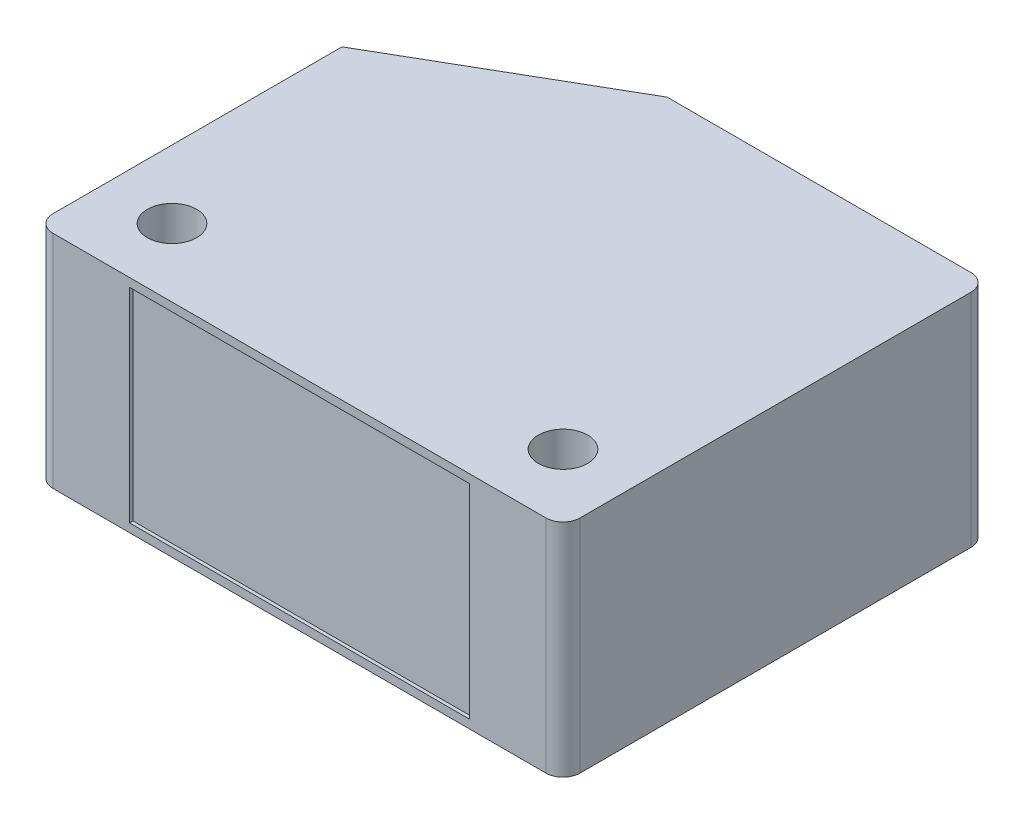
from build123d import *

# Parameters (mm, degrees)
SKETCH1_W           = 31
SKETCH1_H           = 25
SKETCH1_R           = 1.45
BOSS_EXTRUDE1_DEPTH = 13
SKETCH2_W           = 20
SKETCH2_H           = 12
CUT_EXTRUDE1_DEPTH  = 0.2
CUT_EXTRUDE2_DEPTH  = 14
FILLET1_R           = 1


with BuildPart() as part:
    # Sketch1 → Boss-Extrude1 (new body)
    with BuildSketch(Plane(origin=(0, 0, 0), x_dir=(1, 0, 0), z_dir=(0, 1, 0))):
        with Locations((0, -1.439483729)):
            Rectangle(SKETCH1_W, SKETCH1_H)
        with Locations((-11.5, -9.939483729)):
            Circle(SKETCH1_R, mode=Mode.SUBTRACT)
        with Locations((11.5, -9.939483729)):
            Circle(SKETCH1_R, mode=Mode.SUBTRACT)
    extrude(amount=BOSS_EXTRUDE1_DEPTH)

    # Sketch2 → Cut-Extrude1 (cut)
    with BuildSketch(Plane.XY.offset(13.939483729)):
        with Locations((0, 6.5)):
            Rectangle(SKETCH2_W, SKETCH2_H)
    extrude(amount=-CUT_EXTRUDE1_DEPTH, mode=Mode.SUBTRACT)

    # Sketch3 → Cut-Extrude2 (cut, through all)
    with BuildSketch(Plane(origin=(0, 13, 0), x_dir=(1, 0, 0), z_dir=(0, 1, 0))):
        Polygon((-15.5, 4.060516271), (-3.375644347, 11.060516271), (-15.5, 11.060516271), align=None)
    extrude(amount=-CUT_EXTRUDE2_DEPTH, mode=Mode.SUBTRACT)

    # Fillet1
    fillet1_edges = [part.edges().sort_by_distance(p)[0] for p in [
        (15.5, 6.5, 13.939483729),
        (-15.5, 6.5, 13.939483729),
        (15.5, 6.5, -11.060516271),
    ]]
    fillet(fillet1_edges, radius=FILLET1_R)


solid = part.part
